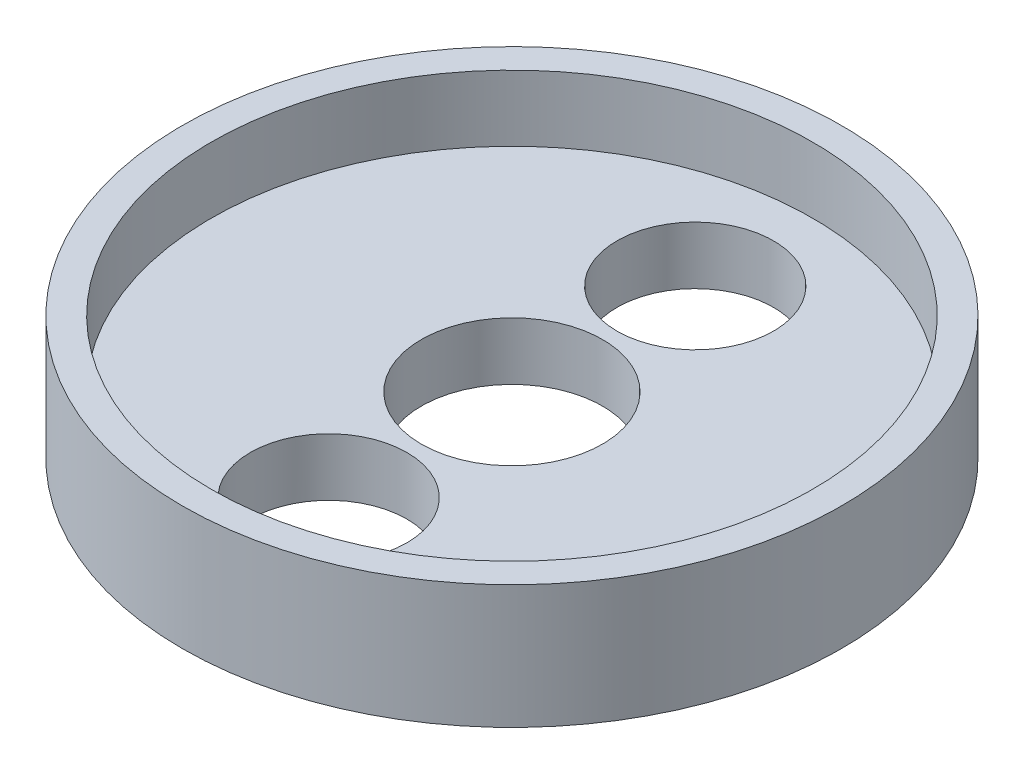
from build123d import *

# Parameters (mm, degrees)
SKETCH4_R        = 20
SKETCH4_R_2      = 5.5
SKETCH4_R_3      = 4.75
LIDBASE_DEPTH    = 7.5
SKETCH5_R        = 18.25
LIDGROOVES_DEPTH = 4


with BuildPart() as part:
    # Sketch4 → LidBase (new body)
    with BuildSketch(Plane(origin=(0, 0, 0), x_dir=(1, 0, 0), z_dir=(0, 1, 0))):
        Circle(SKETCH4_R)
        Circle(SKETCH4_R_2, mode=Mode.SUBTRACT)
        with Locations((0, 11.125)):
            Circle(SKETCH4_R_3, mode=Mode.SUBTRACT)
        with Locations((0, -11.125)):
            Circle(SKETCH4_R_3, mode=Mode.SUBTRACT)
    extrude(amount=LIDBASE_DEPTH)

    # Sketch5 → LidGrooves (cut)
    with BuildSketch(Plane(origin=(0, 7.5, 0), x_dir=(1, 0, 0), z_dir=(0, 1, 0))):
        Circle(SKETCH5_R)
    extrude(amount=-LIDGROOVES_DEPTH, mode=Mode.SUBTRACT)


solid = part.part
